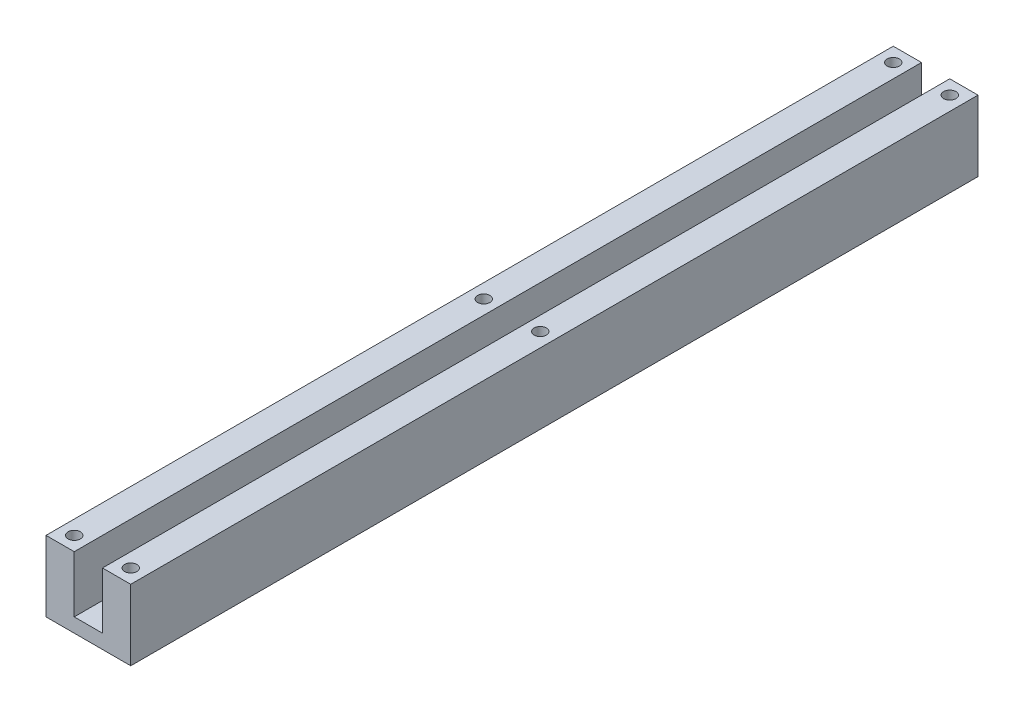
from build123d import *

# Parameters (mm, degrees)
BOSS_EXTRUDE1_DEPTH     = 101.6
SKETCH2_W               = 19.05
SKETCH2_H               = 15.875
CUT_EXTRUDE1_DEPTH      = 6.35
SKETCH3_W               = 19.05
SKETCH3_H               = 15.875
CUT_EXTRUDE2_DEPTH      = 6.35
SKETCH4_R               = 1.3890625
CUT_EXTRUDE3_DEPTH      = 1
CUT_EXTRUDE3_DEPTH_BACK = 16.875


with BuildPart() as part:
    # Sketch1 → Boss-Extrude1 (new body, symmetric)
    with BuildSketch(Plane.XY):
        Polygon((-9.525, 12.7), (-3.175, 12.7), (-3.175, 0), (3.175, 0), (3.175, 12.7), (9.525, 12.7), (9.525, -3.175), (-9.525, -3.175), align=None)
    extrude(amount=BOSS_EXTRUDE1_DEPTH, both=True)

    # Sketch2 → Cut-Extrude1 (cut)
    with BuildSketch(Plane.XY.offset(-101.6)):
        with Locations((0, 4.7625)):
            Rectangle(SKETCH2_W, SKETCH2_H)
    extrude(amount=CUT_EXTRUDE1_DEPTH, mode=Mode.SUBTRACT)

    # Sketch3 → Cut-Extrude2 (cut)
    with BuildSketch(Plane(origin=(0, 0, -95.25), x_dir=(-1, 0, 0), z_dir=(0, 0, -1))):
        with Locations((0, 4.7625)):
            Rectangle(SKETCH3_W, SKETCH3_H)
    extrude(amount=-CUT_EXTRUDE2_DEPTH, mode=Mode.SUBTRACT)

    # Sketch4 → Cut-Extrude3 (cut, two sides)
    with BuildSketch(Plane(origin=(0, 12.7, 0), x_dir=(1, 0, 0), z_dir=(0, 1, 0))) as cut_extrude3_sk:
        with Locations((6.35, 85.725)):
            Circle(SKETCH4_R)
        with Locations((-6.35, 85.725)):
            Circle(SKETCH4_R)
        with Locations((6.35, -6.35)):
            Circle(SKETCH4_R)
        with Locations((-6.35, -6.35)):
            Circle(SKETCH4_R)
        with Locations((6.35, -98.425)):
            Circle(SKETCH4_R)
        with Locations((-6.35, -98.425)):
            Circle(SKETCH4_R)
    extrude(amount=CUT_EXTRUDE3_DEPTH, mode=Mode.SUBTRACT)
    extrude(cut_extrude3_sk.sketch, amount=-CUT_EXTRUDE3_DEPTH_BACK, mode=Mode.SUBTRACT)


solid = part.part
